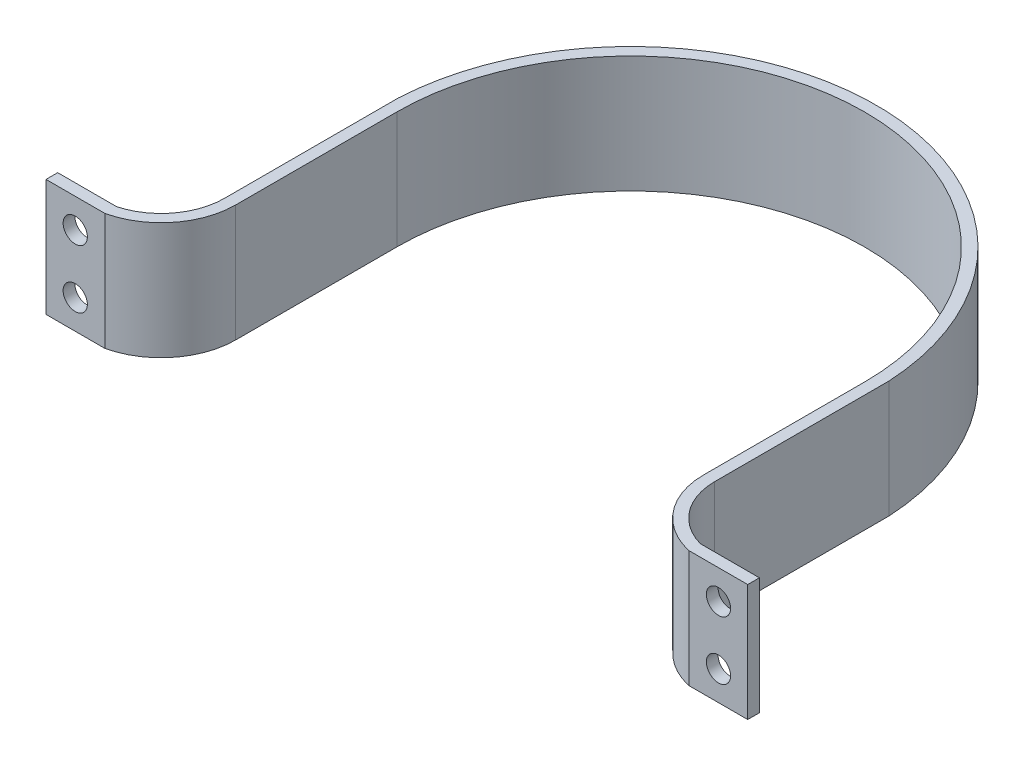
from build123d import *

# Parameters (mm, degrees)
BOSS_EXTRU_1_DEPTH      = 10
ESQUISSE5_R             = 1.036050106
ENL_V_MAT_EXTRU_2_DEPTH = 42


with BuildPart() as part:
    # Esquisse2 → Boss.-Extru.1 (new body)
    with BuildSketch(Plane(origin=(0, 0, 0), x_dir=(1, 0, 0), z_dir=(0, 1, 0))):
        with BuildLine():
            Line((24.963471106, -20), (30.003471106, -20))
            Line((30.003471106, -20), (30.003471106, -19))
            Line((30.003471106, -19), (24.963471106, -19))
            ThreePointArc((24.963471106, -19), (22.092040168, -17.073276579), (20.970186635, -13.802370983))
            Line((20.970186635, -13.802370983), (20.970186635, 1.118602927))
            ThreePointArc((20.970186635, 1.118602927), (0, 21), (-20.970186635, 1.118602927))
            Line((-20.970186635, 1.118602927), (-20.970186635, -13.802370983))
            ThreePointArc((-20.970186635, -13.802370983), (-22.092040168, -17.073276579), (-24.963471106, -19))
            Line((-24.963471106, -19), (-30.003471106, -19))
            Line((-30.003471106, -19), (-30.003471106, -20))
            Line((-30.003471106, -20), (-24.963471106, -20))
            ThreePointArc((-24.963471106, -20), (-21.402232401, -17.765722993), (-20, -13.802370983))
            Line((-20, -13.802370983), (-20, 0))
            ThreePointArc((-20, 0), (0, 20), (20, 0))
            Line((20, 0), (20, -13.802370983))
            ThreePointArc((20, -13.802370983), (21.402232401, -17.765722993), (24.963471106, -20))
        make_face()
    extrude(amount=BOSS_EXTRU_1_DEPTH)

    # Esquisse5 → Enlèv. mat.-Extru.2 (cut, through all)
    with BuildSketch(Plane.XY.offset(20)):
        with Locations((-27.503471106, 7.5)):
            Circle(ESQUISSE5_R)
        with Locations((-27.503471106, 2.5)):
            Circle(ESQUISSE5_R)
        with Locations((27.503471106, 2.5)):
            Circle(ESQUISSE5_R)
        with Locations((27.503471106, 7.5)):
            Circle(ESQUISSE5_R)
    extrude(amount=-ENL_V_MAT_EXTRU_2_DEPTH, mode=Mode.SUBTRACT)


solid = part.part
